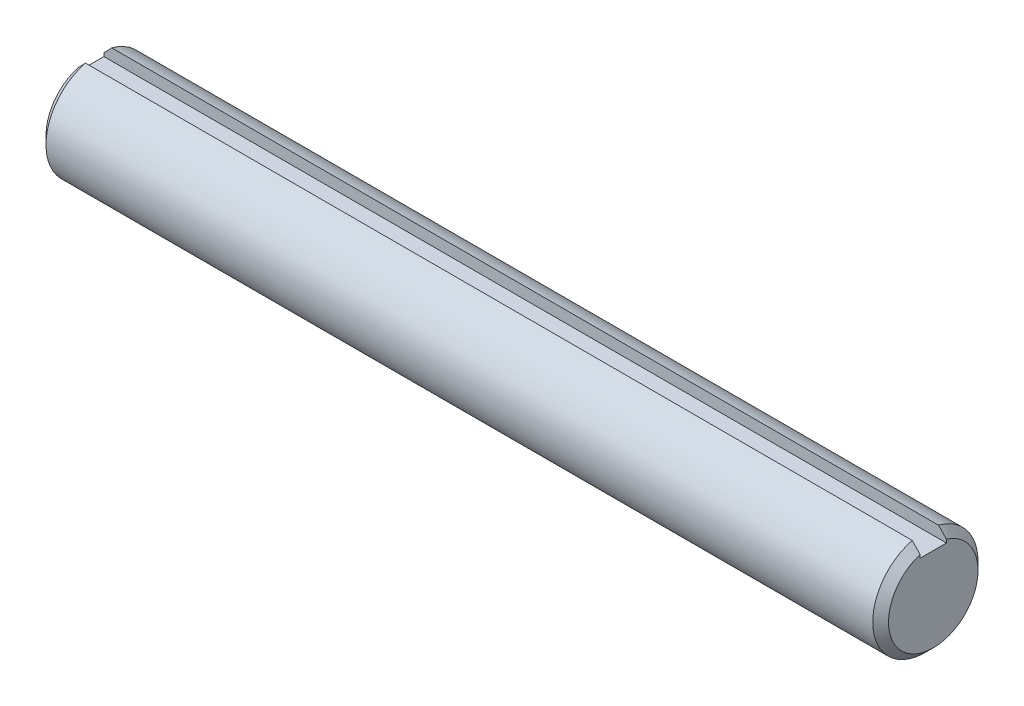
from build123d import *

# Parameters (mm, degrees)
SKETCH1_R           = 19.05
EXTRUDE1_DEPTH      = 152.4
CHAMFER1_SIZE       = 2.8575
SKETCH3_W           = 9.525
SKETCH3_H           = 4.7625
EXTRUDE2_DEPTH      = 153.4
EXTRUDE2_DEPTH_BACK = 153.4


with BuildPart() as part:
    # Sketch1 → Extrude1 (new body, symmetric)
    with BuildSketch(Plane(origin=(0, 0, 0), x_dir=(0, 0, -1), z_dir=(1, 0, 0))):
        Circle(SKETCH1_R)
    extrude(amount=EXTRUDE1_DEPTH, both=True)

    # Chamfer1
    chamfer1_edges = [part.edges().sort_by_distance(p)[0] for p in [
        (-152.4, 0, 19.05),
        (152.4, 0, 19.05),
    ]]
    chamfer(chamfer1_edges, length=CHAMFER1_SIZE)

    # Sketch3 → Extrude2 (cut, two sides)
    with BuildSketch(Plane.ZY) as extrude2_sk:
        with Locations((0, 16.66875)):
            Rectangle(SKETCH3_W, SKETCH3_H)
    extrude(amount=EXTRUDE2_DEPTH, mode=Mode.SUBTRACT)
    extrude(extrude2_sk.sketch, amount=-EXTRUDE2_DEPTH_BACK, mode=Mode.SUBTRACT)


solid = part.part
